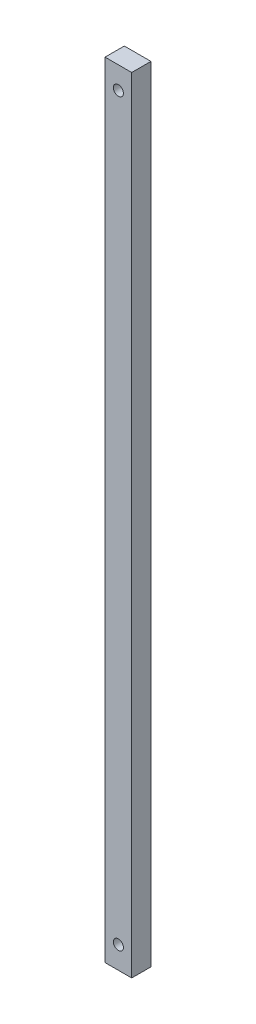
from build123d import *

# Parameters (mm, degrees)
SKETCH_1_W                   = 9
SKETCH_1_H                   = 265
EXTRUDE_1_DEPTH              = 6.5
HOLE_WIZARD_M3_1_D           = 3.4
HOLE_WIZARD_M3_1_DEPTH       = 10.1
HOLE_WIZARD_M3_1_CBORE_D     = 6.5
HOLE_WIZARD_M3_1_CBORE_DEPTH = 3.4
HOLE_WIZARD_M3_1_TIP         = 1.021463052


with BuildPart() as part:
    # 草图1 → 凸台-拉伸1 (new body)
    with BuildSketch(Plane.XY):
        with Locations((4.5, 132.5)):
            Rectangle(SKETCH_1_W, SKETCH_1_H)
    extrude(amount=EXTRUDE_1_DEPTH)

    # M3 六角凹头螺钉的柱形沉头孔1
    with Locations(Plane(origin=(0, 0, 0), x_dir=(-1, 0, 0), z_dir=(0, 0, -1))):
        with Locations((-4.5, 7.5), (-4.5, 257.5)):
            CounterBoreHole(HOLE_WIZARD_M3_1_D / 2, HOLE_WIZARD_M3_1_CBORE_D / 2, HOLE_WIZARD_M3_1_CBORE_DEPTH, depth=HOLE_WIZARD_M3_1_DEPTH)
            with Locations((0, 0, -(HOLE_WIZARD_M3_1_DEPTH + HOLE_WIZARD_M3_1_TIP / 2))):  # 118° drill point
                Cone(0, HOLE_WIZARD_M3_1_D / 2, HOLE_WIZARD_M3_1_TIP, mode=Mode.SUBTRACT)


solid = part.part
